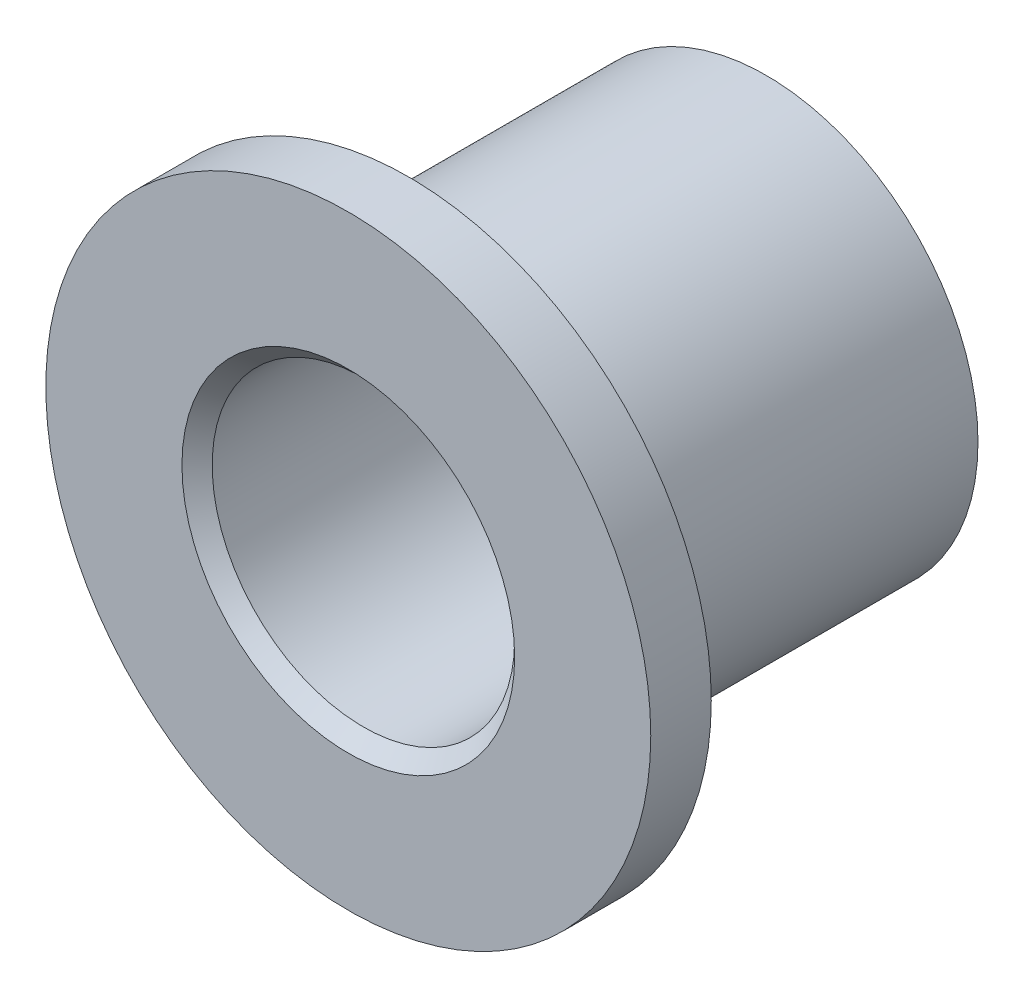
from build123d import *

# Parameters (mm, degrees)
SKETCH_4_R          = 3.5
EXTRUDE_1_DEPTH     = 6
SKETCH_5_R          = 5
EXTRUDE_2_DEPTH     = 1
SKETCH_6_R          = 2.5
CUT_EXTRUDE_1_DEPTH = 8
FILLET_1_R          = 0.4
CHAMFER_1_SIZE      = 0.25
CHAMFER_1_SIZE2     = 0.090992559
CHAMFER_2_SIZE      = 0.25
CHAMFER_3_SIZE      = 0.25


with BuildPart() as part:
    # Эскиз4 → Бобышка-Вытянуть1 (new body)
    with BuildSketch(Plane.XY):
        Circle(SKETCH_4_R)
    extrude(amount=EXTRUDE_1_DEPTH)

    # Эскиз5 → Бобышка-Вытянуть2 (add)
    with BuildSketch(Plane.XY.offset(6)):
        Circle(SKETCH_5_R)
    extrude(amount=EXTRUDE_2_DEPTH)

    # Эскиз6 → Вырез-Вытянуть1 (cut, through all)
    with BuildSketch(Plane.XY.offset(7)):
        Circle(SKETCH_6_R)
    extrude(amount=-CUT_EXTRUDE_1_DEPTH, mode=Mode.SUBTRACT)

    # Скругление1
    fillet_1_edges = [part.edges().sort_by_distance(p)[0] for p in [
        (-3.5, 0, 6),
    ]]
    fillet(fillet_1_edges, radius=FILLET_1_R)

    # Фаска1
    chamfer_1_edges = [part.edges().sort_by_distance(p)[0] for p in [
        (-3.5, 0, 0),
    ]]
    chamfer_1_side = [part.faces().sort_by_distance(p)[0] for p in [
        (-3.401005051, 0, 0),
    ]]
    chamfer(chamfer_1_edges, length=CHAMFER_1_SIZE, length2=CHAMFER_1_SIZE2, reference=chamfer_1_side[0])

    # Фаска2
    chamfer_2_edges = [part.edges().sort_by_distance(p)[0] for p in [
        (-2.5, 0, 0),
    ]]
    chamfer(chamfer_2_edges, length=CHAMFER_2_SIZE)

    # Фаска3
    chamfer_3_edges = [part.edges().sort_by_distance(p)[0] for p in [
        (-2.5, 0, 7),
    ]]
    chamfer(chamfer_3_edges, length=CHAMFER_3_SIZE)


solid = part.part
